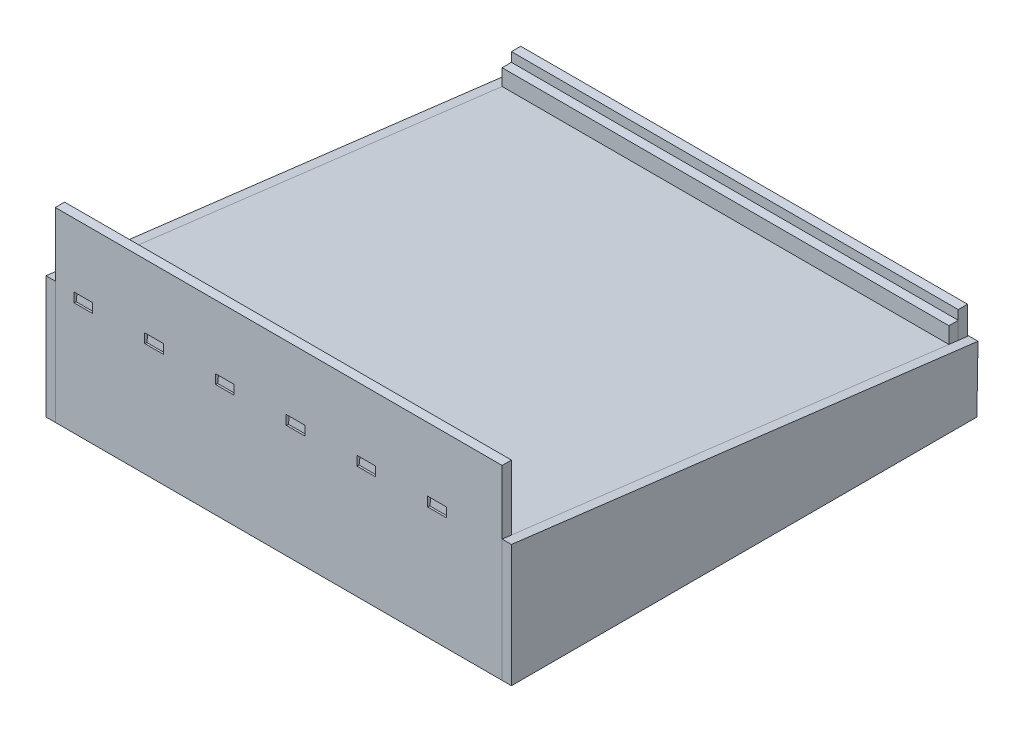
from build123d import *

# Parameters (mm, degrees)
SKETCH1_W            = 304.8
SKETCH1_H            = 304.8
BOSS_EXTRUDE1_DEPTH  = 6.35
SKETCH2_W            = 304.8
SKETCH2_H            = 127
BOSS_EXTRUDE2_DEPTH  = 6.35
SKETCH4_W            = 304.8
SKETCH4_H            = 38.1
BOSS_EXTRUDE3_DEPTH  = 6.35
SKETCH7_W            = 304.8
SKETCH7_H            = 304.8
BOSS_EXTRUDE4_DEPTH  = 6.35
SKETCH10_W           = 304.8
SKETCH10_H           = 317.5
BOSS_EXTRUDE6_DEPTH  = 6.35
SKETCH16_W           = 12.7
SKETCH16_H           = 7.62
CUT_EXTRUDE3_DEPTH   = 6.35
LPATTERN1_COUNT      = 6
LPATTERN1_PITCH      = 48.26
BOSS_EXTRUDE23_DEPTH = 6.35
LPATTERN3_COUNT      = 2
LPATTERN3_PITCH      = 311.15
SKETCH23_W           = 304.8
SKETCH23_H           = 25.4
BOSS_EXTRUDE24_DEPTH = 6.35
LPATTERN4_COUNT      = 2
LPATTERN4_PITCH      = 6.35
SKETCH24_W           = 304.8
SKETCH24_H           = 6.35
CUT_EXTRUDE4_DEPTH   = 6.35


with BuildPart() as part:
    # Sketch1 → Boss-Extrude1 (new body)
    with BuildSketch(Plane(origin=(0, 0, 0), x_dir=(1, 0, 0), z_dir=(0, 1, 0))):
        with Locations((152.4, 152.4)):
            Rectangle(SKETCH1_W, SKETCH1_H)
    extrude(amount=BOSS_EXTRUDE1_DEPTH)

    # Sketch2 → Boss-Extrude2 (add)
    with BuildSketch(Plane.XY):
        with Locations((152.4, 63.5)):
            Rectangle(SKETCH2_W, SKETCH2_H)
    extrude(amount=BOSS_EXTRUDE2_DEPTH)

    # Sketch4 → Boss-Extrude3 (add)
    with BuildSketch(Plane(origin=(0, 0, -304.8), x_dir=(-1, 0, 0), z_dir=(0, 0, -1))):
        with Locations((-152.4, 19.05)):
            Rectangle(SKETCH4_W, SKETCH4_H)
    extrude(amount=BOSS_EXTRUDE3_DEPTH)

    # Sketch7 → Boss-Extrude4 (add)
    with BuildSketch(Plane(origin=(0, 38.1, 0), x_dir=(1, 0, 0), z_dir=(0, 1, 0))):
        with Locations((152.4, 152.4)):
            Rectangle(SKETCH7_W, SKETCH7_H)
    extrude(amount=-BOSS_EXTRUDE4_DEPTH)

    # Sketch16 → Cut-Extrude3 (cut)
    with BuildSketch(Plane(origin=(0, 75.171132493, -9.229854496), x_dir=(1, 0, 0), z_dir=(0, 0.992546152, -0.121869343))):
        with Locations((19.05, -17.970074675)):
            Rectangle(SKETCH16_W, SKETCH16_H)
    cut_extrude3 = extrude(amount=CUT_EXTRUDE3_DEPTH, mode=Mode.SUBTRACT)

    # LPattern1: Cut-Extrude3 ×6
    with Locations(*[(i * LPATTERN1_PITCH, 0, 0) for i in range(1, LPATTERN1_COUNT)]):
        add(cut_extrude3, mode=Mode.SUBTRACT)


with BuildPart() as body_2:
    # Sketch10 → Boss-Extrude6 (new body)
    with BuildSketch(Plane(origin=(0, 75.171132493, -9.229854496), x_dir=(1, 0, 0), z_dir=(0, 0.992546152, -0.121869343))):
        with Locations((152.4, 145.437513099)):
            Rectangle(SKETCH10_W, SKETCH10_H)
    extrude(amount=BOSS_EXTRUDE6_DEPTH)


with BuildPart() as body_3:
    # Sketch22 → Boss-Extrude23 (new body)
    with BuildSketch(Plane(origin=(0, 0, 0), x_dir=(0, 0, -1), z_dir=(1, 0, 0))):
        Polygon((-6.35, 0), (-6.35, 83.481785478), (311.923870331, 44.402668063), (311.15, 0), align=None)
    boss_extrude23 = extrude(amount=-BOSS_EXTRUDE23_DEPTH)


with BuildPart() as lpattern3_1:
    # LPattern3: Boss-Extrude23 ×2
    with Locations(*[(i * LPATTERN3_PITCH, 0, 0) for i in range(1, LPATTERN3_COUNT)]):
        add(boss_extrude23)


with BuildPart() as body_5:
    # Sketch23 → Boss-Extrude24 (new body)
    with BuildSketch(Plane(origin=(0, 0, -311.15), x_dir=(-1, 0, 0), z_dir=(0, 0, -1))):
        with Locations((-152.4, 50.8)):
            Rectangle(SKETCH23_W, SKETCH23_H)
    boss_extrude24 = extrude(amount=-BOSS_EXTRUDE24_DEPTH)


with BuildPart() as lpattern4_1:
    # LPattern4: Boss-Extrude24 ×2
    with Locations(*[(0, 0, i * LPATTERN4_PITCH) for i in range(1, LPATTERN4_COUNT)]):
        add(boss_extrude24)

    # Sketch24 → Cut-Extrude4 (cut)
    with BuildSketch(Plane.XY.offset(-298.45)):
        with Locations((152.4, 60.325)):
            Rectangle(SKETCH24_W, SKETCH24_H)
    extrude(amount=-CUT_EXTRUDE4_DEPTH, mode=Mode.SUBTRACT)


solid = Compound([part.part, body_2.part, body_3.part, lpattern3_1.part, body_5.part, lpattern4_1.part])
